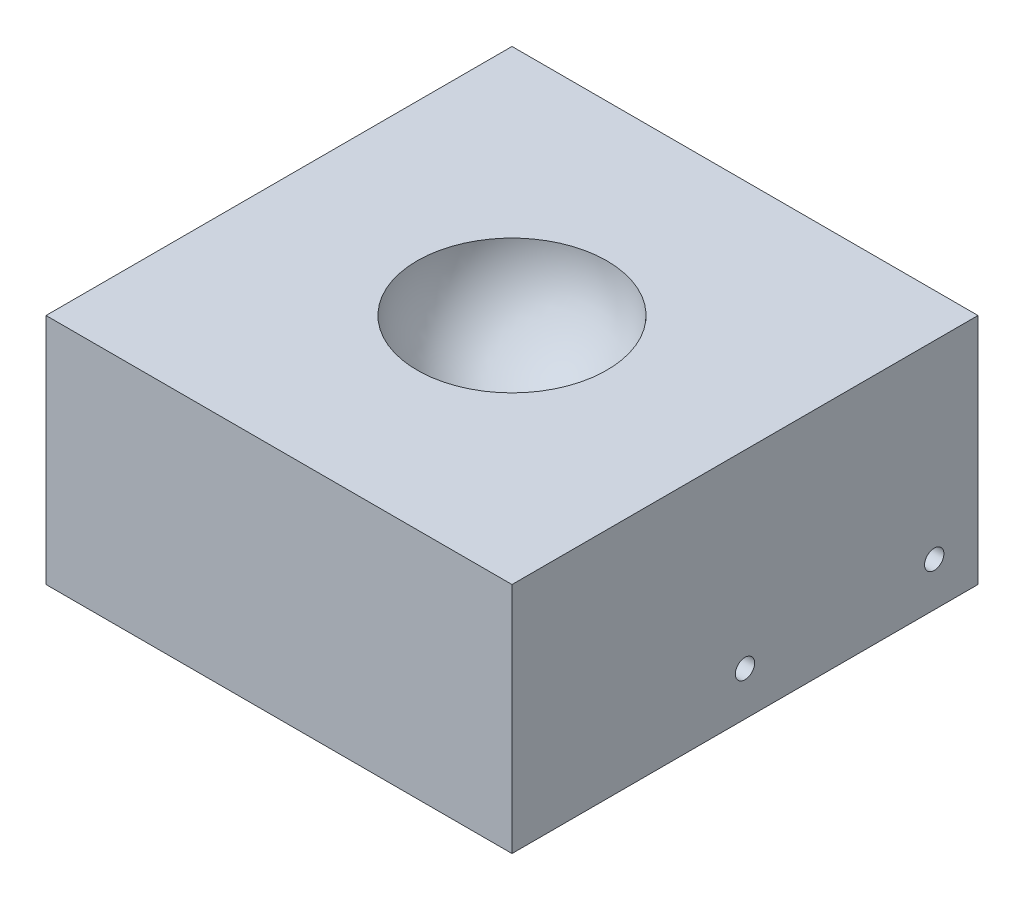
from build123d import *

# Parameters (mm, degrees)
SKETCH1_W               = 172
SKETCH1_H               = 172
BOSS_EXTRUDE1_DEPTH     = 86
SKETCH3_R               = 3.5687
CUT_EXTRUDE1_DEPTH      = 87
CUT_EXTRUDE1_DEPTH_BACK = 87


with BuildPart() as part:
    # Sketch1 → Boss-Extrude1 (new body)
    with BuildSketch(Plane(origin=(0, 0, 0), x_dir=(1, 0, 0), z_dir=(0, 1, 0))):
        Rectangle(SKETCH1_W, SKETCH1_H)
    extrude(amount=-BOSS_EXTRUDE1_DEPTH)

    # Sketch2 → Cut-Revolve1 (revolve, cut)
    with BuildSketch(Plane.XY):
        with BuildLine():
            Line((0, -35), (0, 0))
            Line((0, 0), (35, 0))
            ThreePointArc((35, 0), (24.748737342, -24.748737342), (0, -35))
        make_face()
    revolve(axis=Axis((0, -35, 0), (0, 1, 0)), mode=Mode.SUBTRACT)

    # Sketch3 → Cut-Extrude1 (cut, two sides)
    with BuildSketch(Plane(origin=(0, 0, 0), x_dir=(0, 0, -1), z_dir=(1, 0, 0))) as cut_extrude1_sk:
        with Locations((0, -69.85)):
            Circle(SKETCH3_R)
        with Locations((69.85, -69.85)):
            Circle(SKETCH3_R)
    extrude(amount=CUT_EXTRUDE1_DEPTH, mode=Mode.SUBTRACT)
    extrude(cut_extrude1_sk.sketch, amount=-CUT_EXTRUDE1_DEPTH_BACK, mode=Mode.SUBTRACT)


solid = part.part
